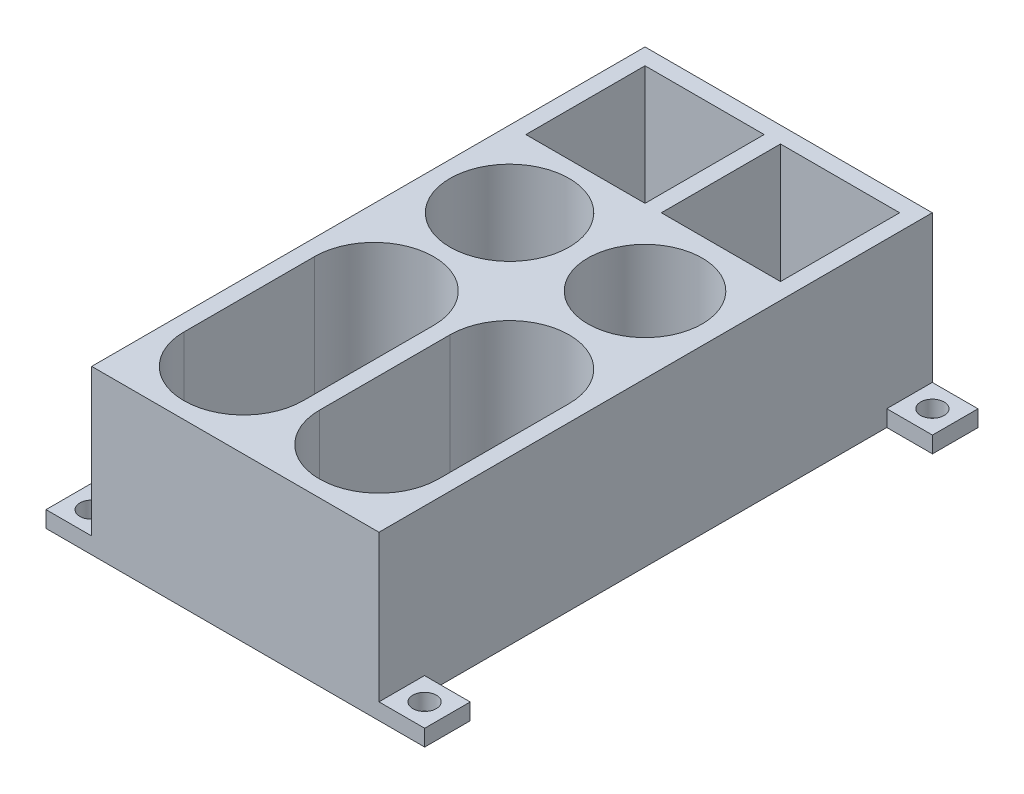
from build123d import *

# Parameters (mm, degrees)
SKIZZE1_W                       = 44
SKIZZE1_H                       = 84.75
SKIZZE1_R                       = 9.125
SKIZZE1_R_2                     = 8.753791834
SKIZZE1_W_2                     = 18.25
SKIZZE1_H_2                     = 18.25
AUFSATZ_LINEAR_AUSTRAGEN1_DEPTH = 25
SKIZZE2_W                       = 7
SKIZZE2_H                       = 6.973629197
SKIZZE2_R                       = 1.8
AUFSATZ_LINEAR_AUSTRAGEN2_DEPTH = 2.5
SPIEGELN2_COPY_1_SKETCH_W       = 7
SPIEGELN2_COPY_1_SKETCH_H       = 6.973629197
SPIEGELN2_COPY_1_SKETCH_R       = 1.8
SPIEGELN2_COPY_1_DEPTH          = 2.5


with BuildPart() as part:
    # Skizze1 → Aufsatz-Linear austragen1 (new body)
    with BuildSketch(Plane(origin=(0, 0, 0), x_dir=(1, 0, 0), z_dir=(0, 1, 0))):
        Rectangle(SKIZZE1_W, SKIZZE1_H)
        with Locations((-10.375, 10)):
            Circle(SKIZZE1_R, mode=Mode.SUBTRACT)
        with Locations((10.375, 10)):
            Circle(SKIZZE1_R_2, mode=Mode.SUBTRACT)
        with Locations((-10.375, 30.75)):
            Rectangle(SKIZZE1_W_2, SKIZZE1_H_2, mode=Mode.SUBTRACT)
        with Locations((10.375, 30.75)):
            Rectangle(SKIZZE1_W_2, SKIZZE1_H_2, mode=Mode.SUBTRACT)
        with BuildLine():
            Line((-1.25, -10.75), (-1.25, -30.75))
            ThreePointArc((-1.25, -30.75), (-10.375, -39.875), (-19.5, -30.75))
            Line((-19.5, -30.75), (-19.5, -10.75))
            ThreePointArc((-19.5, -10.75), (-10.375, -1.625), (-1.25, -10.75))
        make_face(mode=Mode.SUBTRACT)
        with BuildLine():
            Line((19.5, -10.75), (19.5, -30.75))
            ThreePointArc((19.5, -30.75), (10.375, -39.875), (1.25, -30.75))
            Line((1.25, -30.75), (1.25, -10.75))
            ThreePointArc((1.25, -10.75), (10.375, -1.625), (19.5, -10.75))
        make_face(mode=Mode.SUBTRACT)
    extrude(amount=AUFSATZ_LINEAR_AUSTRAGEN1_DEPTH)

    # Skizze2 → Aufsatz-Linear austragen2 (add)
    with BuildSketch(Plane.XZ):
        with Locations((-25.5, 38.888185401)):
            Rectangle(SKIZZE2_W, SKIZZE2_H)
        with Locations((-25.5, 38.888185402)):
            Circle(SKIZZE2_R, mode=Mode.SUBTRACT)
    aufsatz_linear_austragen2 = extrude(amount=-AUFSATZ_LINEAR_AUSTRAGEN2_DEPTH)

    # Spiegeln1: Aufsatz-Linear austragen2 across plane
    add(aufsatz_linear_austragen2.mirror(Plane(origin=(0, 0, 0), x_dir=(0, 0, 1), z_dir=(1, 0, 0))))

    # Spiegeln2: Aufsatz-Linear austragen2 across plane
    add(aufsatz_linear_austragen2.mirror(Plane.XY))

    # Spiegeln2 copy 1 sketch → Spiegeln2 copy 1 (add)
    with BuildSketch(Plane(origin=(0, 0, 0), x_dir=(-1, 0, 0), z_dir=(0, -1, 0))):
        with Locations((-25.5, 38.888185401)):
            Rectangle(SPIEGELN2_COPY_1_SKETCH_W, SPIEGELN2_COPY_1_SKETCH_H)
        with Locations((-25.5, 38.888185402)):
            Circle(SPIEGELN2_COPY_1_SKETCH_R, mode=Mode.SUBTRACT)
    extrude(amount=-SPIEGELN2_COPY_1_DEPTH)


solid = part.part
